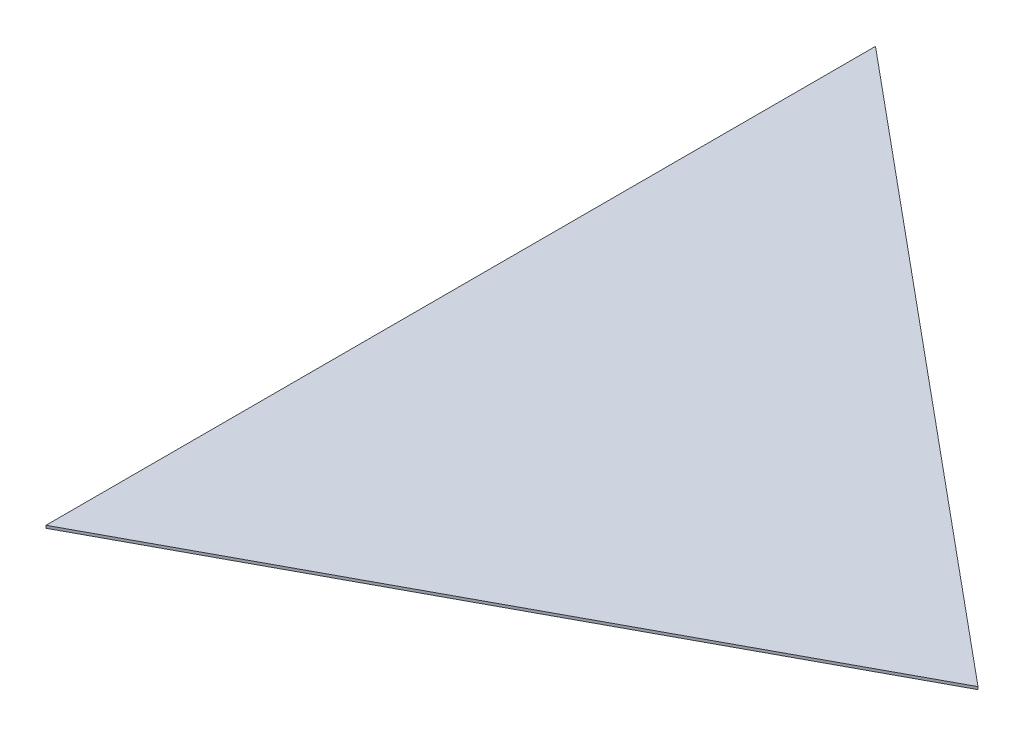
from build123d import *

# Parameters (mm, degrees)
BOSS_EXTRUDE1_DEPTH = 1.5875


with BuildPart() as part:
    # Sketch1 → Boss-Extrude1 (new body)
    with BuildSketch(Plane(origin=(0, 0, 0), x_dir=(1, 0, 0), z_dir=(0, 1, 0))):
        Polygon((0, 0), (0, 501.904), (366.522, 197.408210978), align=None)
    extrude(amount=BOSS_EXTRUDE1_DEPTH)


solid = part.part
